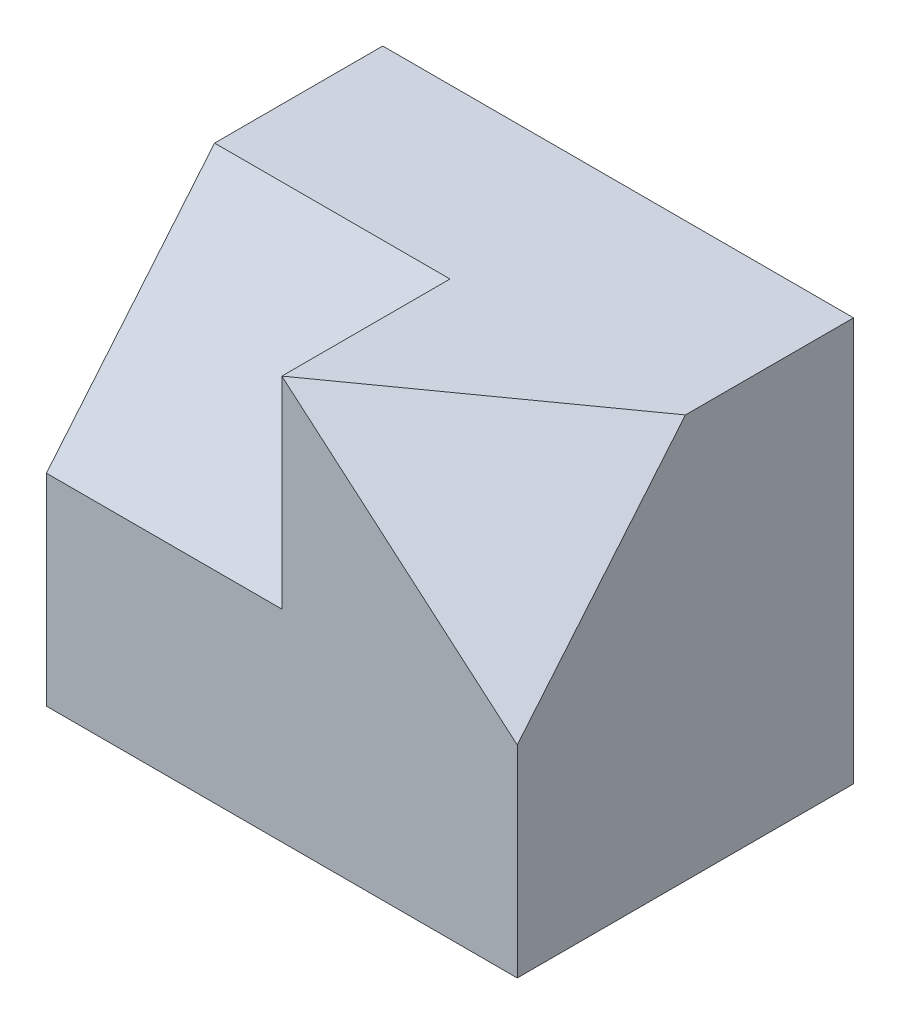
from build123d import *

# Parameters (mm, degrees)
ESBO_O1_W             = 70
ESBO_O1_H             = 50
EXTRUS_O1_DEPTH       = 60
CORTE_EXTRUS_O2_DEPTH = 35


with BuildPart() as part:
    # Esboço1 → Extrusão1 (new body)
    with BuildSketch(Plane(origin=(0, 0, 0), x_dir=(1, 0, 0), z_dir=(0, 1, 0))):
        Rectangle(ESBO_O1_W, ESBO_O1_H)
    extrude(amount=EXTRUS_O1_DEPTH)

    # Esboço5 → Corte-extrusão2 (cut)
    with BuildSketch(Plane.ZY.offset(35)):
        Polygon((0, 60), (25, 30), (25, 60), align=None)
    extrude(amount=-CORTE_EXTRUS_O2_DEPTH, mode=Mode.SUBTRACT)

    # Corte de superfície4
    split(bisect_by=Plane(origin=(24.299305734, 28.349190023, 34.019028028), x_dir=(-0.876685828, 0.30796926, 0.369563112), z_dir=(-0.481063363, -0.56124059, -0.673488708)), keep=Keep.TOP)


solid = part.part
